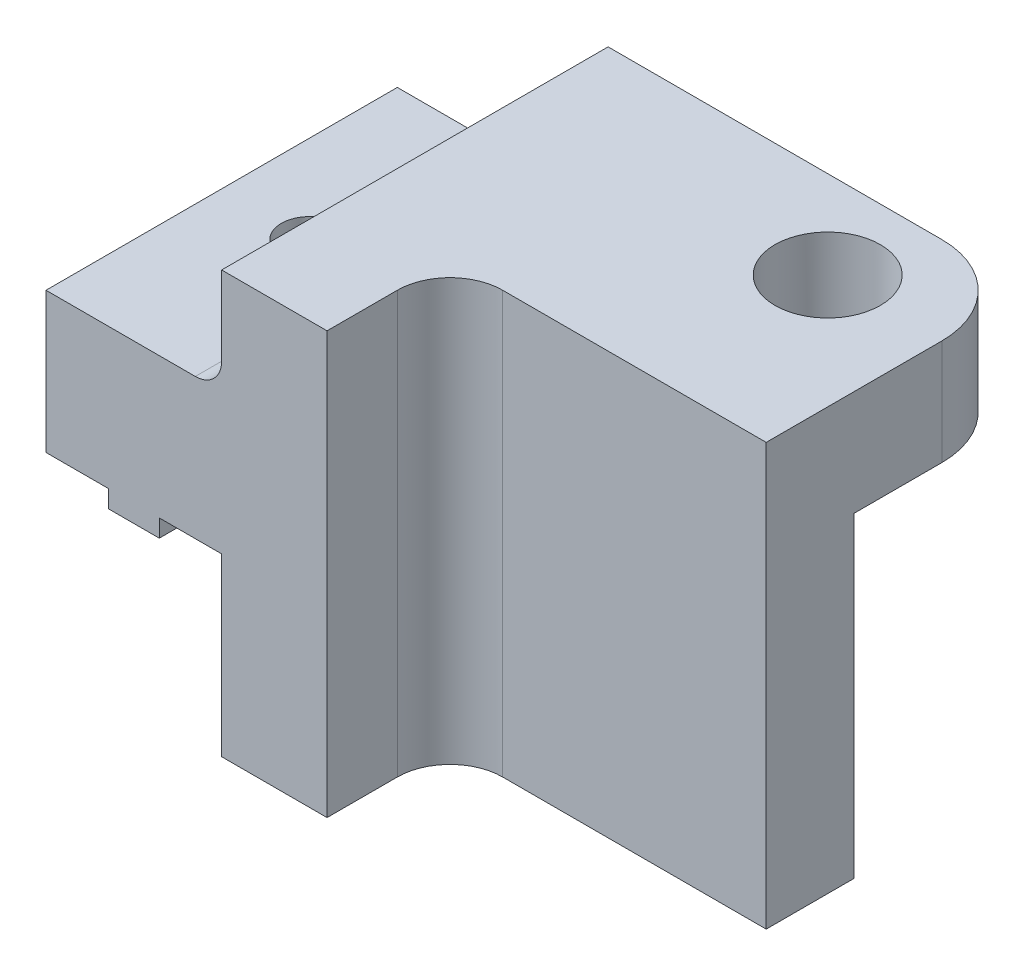
from build123d import *

# Parameters (mm, degrees)
MAIN_DEPTH                   = 22
ESQUISSE2_W                  = 10
ESQUISSE2_H                  = 8
ENL_V_MAT_EXTRU_1_DEPTH      = 19
ESQUISSE3_W                  = 21
ESQUISSE3_H                  = 10
ENL_V_MAT_EXTRU_2_DEPTH      = 10
ESQUISSE4_R                  = 3
ENL_V_MAT_EXTRU_3_DEPTH      = 1
ENL_V_MAT_EXTRU_3_DEPTH_BACK = 25
CONG_2_R                     = 5
ENL_V_START                  = -18
ESQUISSE6_W                  = 7
ESQUISSE6_H                  = 24
ENL_V_MAT_EXTRU_4_DEPTH      = 18
SKETCH1_W                    = 10
SKETCH1_H                    = 2
CUT_EXTRUDE1_DEPTH           = 19
SKETCH2_R                    = 1.6
CUT_EXTRUDE2_DEPTH           = 19
FILLET1_R                    = 1.5
CONG_3_R                     = 3
SKETCH3_W                    = 22
SKETCH3_H                    = 24
CUT_EXTRUDE3_DEPTH           = 39


with BuildPart() as part:
    # Esquisse1 → Main (new body)
    with BuildSketch(Plane.XY):
        Polygon((-12, -12), (12, -12), (12, -2), (15.55, -2), (15.55, -3), (18.45, -3), (18.45, -2), (22, -2), (22, 6), (12, 6), (12, 12), (-12, 12), align=None)
    extrude(amount=MAIN_DEPTH)

    # Esquisse2 → Enlèv. mat.-Extru.1 (cut, through all)
    with BuildSketch(Plane(origin=(6, 0, 0), x_dir=(0, 0, -1), z_dir=(1, 0, 0))):
        with Locations((-5, 2)):
            Rectangle(ESQUISSE2_W, ESQUISSE2_H)
    extrude(amount=-ENL_V_MAT_EXTRU_1_DEPTH, mode=Mode.SUBTRACT)

    # Esquisse3 → Enlèv. mat.-Extru.2 (cut)
    with BuildSketch(Plane(origin=(0, 0, 0), x_dir=(-1, 0, 0), z_dir=(0, 0, -1))):
        with Locations((1.5, -7)):
            Rectangle(ESQUISSE3_W, ESQUISSE3_H)
    extrude(amount=-ENL_V_MAT_EXTRU_2_DEPTH, mode=Mode.SUBTRACT)

    # Esquisse4 → Enlèv. mat.-Extru.3 (cut, two sides)
    with BuildSketch(Plane(origin=(0, 12, 0), x_dir=(1, 0, 0), z_dir=(0, 1, 0))) as enl_v_mat_extru_3_sk:
        with Locations((-5.5, -5)):
            Circle(ESQUISSE4_R)
    extrude(amount=ENL_V_MAT_EXTRU_3_DEPTH, mode=Mode.SUBTRACT)
    extrude(enl_v_mat_extru_3_sk.sketch, amount=-ENL_V_MAT_EXTRU_3_DEPTH_BACK, mode=Mode.SUBTRACT)

    # Congé2
    cong_2_edges = [part.edges().sort_by_distance(p)[0] for p in [
        (-12, 9, 0),
        (6, 6, 5),
    ]]
    fillet(cong_2_edges, radius=CONG_2_R)

    # Esquisse6 → Enlèv. mat.-Extru.4 (cut)
    with BuildSketch(Plane.ZY.offset(12).offset(ENL_V_START)):
        with Locations((18.5, 0)):
            Rectangle(ESQUISSE6_W, ESQUISSE6_H)
    extrude(amount=ENL_V_MAT_EXTRU_4_DEPTH, mode=Mode.SUBTRACT)

    # Sketch1 → Cut-Extrude1 (cut, through all)
    with BuildSketch(Plane(origin=(0, 6, 0), x_dir=(1, 0, 0), z_dir=(0, 1, 0))):
        with Locations((17, -1)):
            Rectangle(SKETCH1_W, SKETCH1_H)
    extrude(amount=-CUT_EXTRUDE1_DEPTH, mode=Mode.SUBTRACT)

    # Sketch2 → Cut-Extrude2 (cut, through all)
    with BuildSketch(Plane(origin=(0, 6, 0), x_dir=(1, 0, 0), z_dir=(0, 1, 0))):
        with Locations((17, -12)):
            Circle(SKETCH2_R)
    extrude(amount=-CUT_EXTRUDE2_DEPTH, mode=Mode.SUBTRACT)

    # Fillet1
    fillet1_edges = [part.edges().sort_by_distance(p)[0] for p in [
        (12, 6, 12),
    ]]
    fillet(fillet1_edges, radius=FILLET1_R)

    # Congé3
    cong_3_edges = [part.edges().sort_by_distance(p)[0] for p in [
        (6, 0, 15),
    ]]
    fillet(cong_3_edges, radius=CONG_3_R)


with BuildPart() as body_2:
    # Mirror1: mirrored copy
    add(part.part.mirror(Plane(origin=(26, 0, 0), x_dir=(0, 0, 1), z_dir=(1, 0, 0))))


with BuildPart() as part_1:
    add(part.part)

    # Sketch3 → Cut-Extrude3 (cut, through all)
    with BuildSketch(Plane(origin=(26, 0, 0), x_dir=(0, 0, -1), z_dir=(1, 0, 0))):
        with Locations((-11, 0)):
            Rectangle(SKETCH3_W, SKETCH3_H)
    extrude(amount=-CUT_EXTRUDE3_DEPTH, mode=Mode.SUBTRACT)


solid = body_2.part
